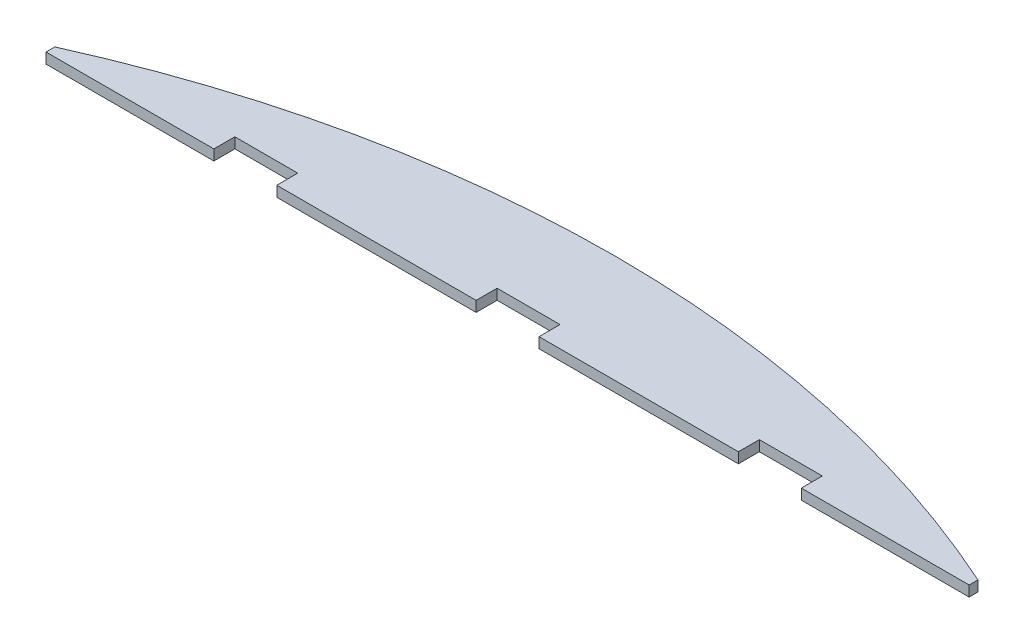
from build123d import *

# Parameters (mm, degrees)
EXTRUDE_1_DEPTH     = 1
SKETCH_2_W          = 6
SKETCH_2_H          = 4
CUT_EXTRUDE_1_DEPTH = 2


with BuildPart() as part:
    # 草图1 → 凸台-拉伸1 (new body)
    with BuildSketch(Plane(origin=(0, 0, 0), x_dir=(1, 0, 0), z_dir=(0, 1, 0))):
        with BuildLine():
            Line((-30, -3), (-44, -3))
            Line((-44, -3), (-44, -2.158291102))
            ThreePointArc((-44, -2.158291102), (0, 7.280007457), (44, -2.158291102))
            Line((44, -2.158291102), (44, -3))
            Line((44, -3), (30, -3))
            Line((30, -3), (-30, -3))
        make_face()
    extrude(amount=EXTRUDE_1_DEPTH)

    # 草图2 → 切除-拉伸1 (cut, through all)
    with BuildSketch(Plane.XZ):
        with Locations((0, 3)):
            Rectangle(SKETCH_2_W, SKETCH_2_H)
        with Locations((25, 3)):
            Rectangle(SKETCH_2_W, SKETCH_2_H)
        with Locations((-25, 3)):
            Rectangle(SKETCH_2_W, SKETCH_2_H)
    extrude(amount=-CUT_EXTRUDE_1_DEPTH, mode=Mode.SUBTRACT)


solid = part.part
